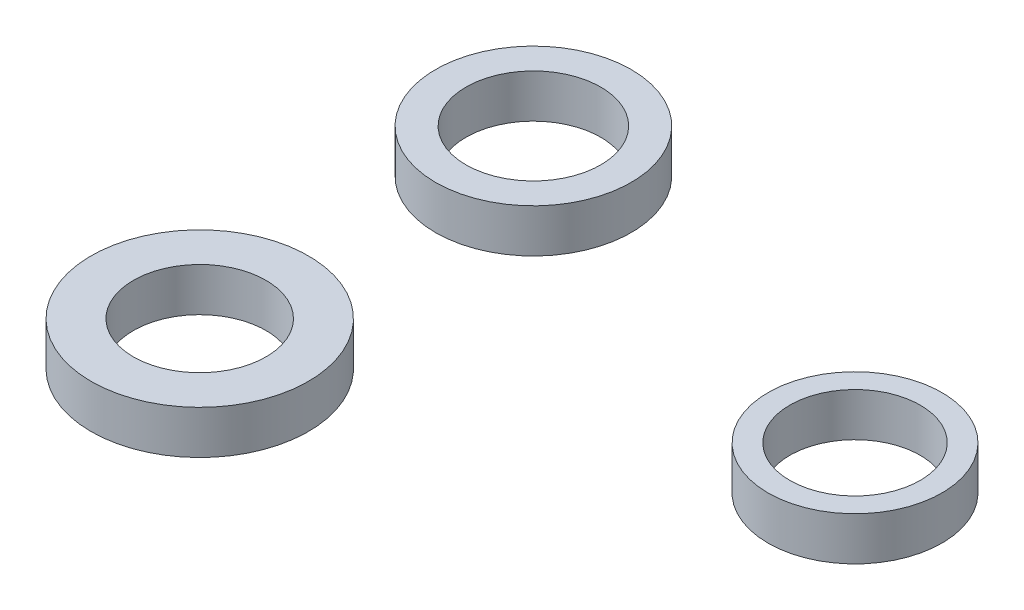
from build123d import *

# Parameters (mm, degrees)
SKETCH_1_R        = 4
SKETCH_1_R_2      = 3
EXTRUDE_1_DEPTH   = 2
SKETCH_1_R_3      = 4.5
SKETCH_1_R_4      = 3.1
EXTRUDE_1_2_DEPTH = 2
SKETCH_1_R_5      = 5
SKETCH_1_R_6      = 3.05
EXTRUDE_1_3_DEPTH = 2


with BuildPart() as part:
    # 草图1 → 凸台-拉伸1 (new body)
    with BuildSketch(Plane(origin=(0, 0, 0), x_dir=(1, 0, 0), z_dir=(0, 1, 0))):
        with Locations((-33.103091259, 2.840690579)):
            Circle(SKETCH_1_R)
        with Locations((-33.103091259, 2.840690579)):
            Circle(SKETCH_1_R_2, mode=Mode.SUBTRACT)
    extrude(amount=EXTRUDE_1_DEPTH)


with BuildPart() as body_2:
    # 草图1 → Extrude 1 2 (new body)
    with BuildSketch(Plane(origin=(0, 0, 0), x_dir=(1, 0, 0), z_dir=(0, 1, 0))):
        with Locations((-53.117309994, 8.062192842)):
            Circle(SKETCH_1_R_3)
        with Locations((-53.117309994, 8.062192842)):
            Circle(SKETCH_1_R_4, mode=Mode.SUBTRACT)
    extrude(amount=EXTRUDE_1_2_DEPTH)


with BuildPart() as body_3:
    # 草图1 → Extrude 1 3 (new body)
    with BuildSketch(Plane(origin=(0, 0, 0), x_dir=(1, 0, 0), z_dir=(0, 1, 0))):
        with Locations((-53.117309994, -7.283243837)):
            Circle(SKETCH_1_R_5)
        with Locations((-53.117309994, -7.283243837)):
            Circle(SKETCH_1_R_6, mode=Mode.SUBTRACT)
    extrude(amount=EXTRUDE_1_3_DEPTH)


solid = Compound([part.part, body_2.part, body_3.part])
